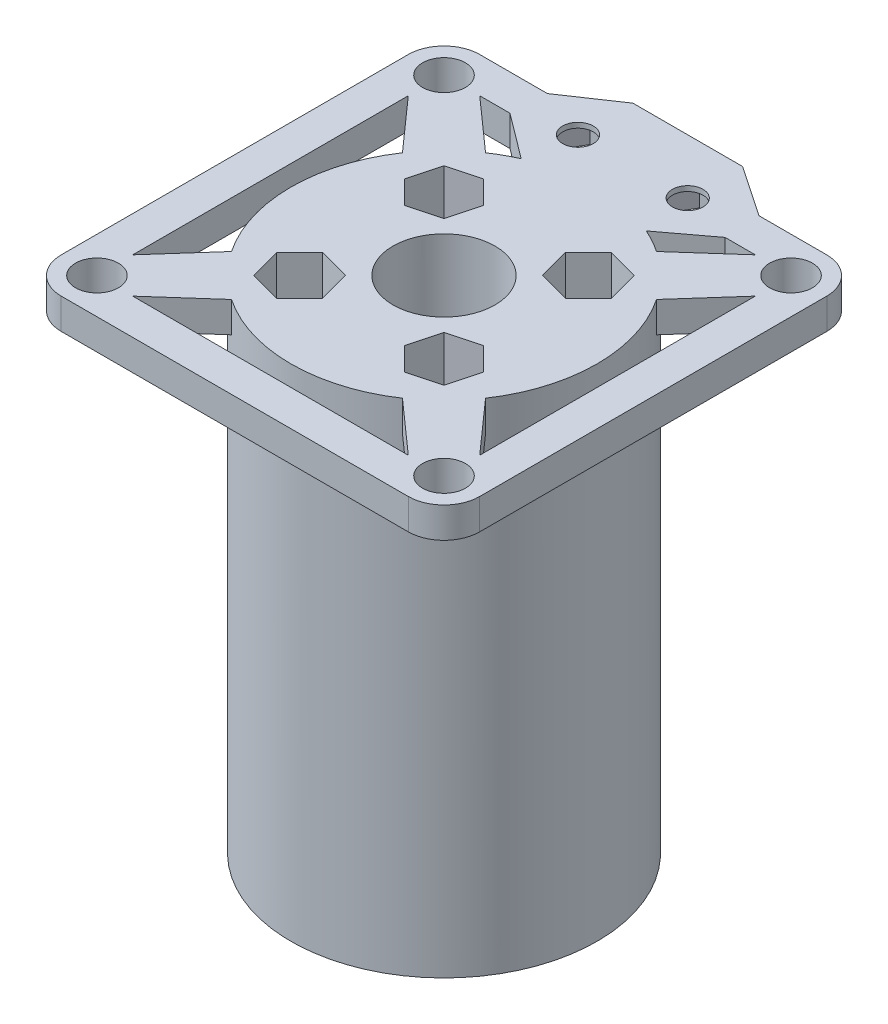
from build123d import *

# Parameters (mm, degrees)
SKETCH_1_R               = 15
SKETCH_1_R_2             = 5
EXTRUDE_4_DEPTH          = 3
SKETCH_1_R_3             = 3.5
SKETCH_1_R_4             = 2.1
EXTRUDE_4_2_DEPTH        = 3
EXTRUDE_5_DEPTH          = 3
PATTERN_CIRCULAR_2_COUNT = 4
SKETCH_6_R               = 3.5
SKETCH_6_R_2             = 2.1
EXTRUDE_6_DEPTH          = 3
PATTERN_CIRCULAR_3_COUNT = 4
SKETCH_7_R               = 15
SKETCH_7_R_2             = 5
EXTRUDE_7_DEPTH          = 46
CUT_EXTRUDE_1_DEPTH      = 46
PATTERN_CIRCULAR_4_COUNT = 4
SKETCH_11_R              = 1.5
CUT_EXTRUDE_2_DEPTH      = 3
PATTERN_CIRCULAR_5_COUNT = 4
EXTRUDE_8_DEPTH          = 3
EXTRUDE_9_DEPTH          = 3
EXTRUDE_10_DEPTH         = 3
EXTRUDE_11_DEPTH         = 3
EXTRUDE_13_DEPTH         = 3
EXTRUDE_14_DEPTH         = 3
CUT_EXTRUDE_3_DEPTH      = 2.5
SKETCH_19_R              = 1.5
CUT_EXTRUDE_4_DEPTH      = 2.5
SKETCH_20_R              = 1.5
CUT_EXTRUDE_5_DEPTH      = 2.5
SKETCH_21_R              = 15
SKETCH_21_R_2            = 5
EXTRUDE_15_DEPTH         = 3
SKETCH_22_R              = 1.5
CUT_EXTRUDE_6_DEPTH      = 3
PATTERN_CIRCULAR_6_COUNT = 4
EXTRUDE_16_DEPTH         = 3
CUT_EXTRUDE_7_DEPTH      = 3
SKETCH_25_R              = 15
SKETCH_25_R_2            = 5
EXTRUDE_17_DEPTH         = 43
SKETCH_27_R              = 1.5
CUT_EXTRUDE_8_DEPTH      = 46
SKETCH_28_R              = 2.75
CUT_EXTRUDE_9_DEPTH      = 43
SKETCH_29_R              = 1.5
CUT_EXTRUDE_10_DEPTH     = 46
PATTERN_CIRCULAR_7_COUNT = 4
CUT_EXTRUDE_11_DEPTH     = 43
PATTERN_CIRCULAR_8_COUNT = 4
SKETCH_31_R              = 26.244176336
CUT_EXTRUDE_12_DEPTH     = 100


with BuildPart() as part:
    # 草图1 → 凸台-拉伸4 (new body)
    with BuildSketch(Plane(origin=(0, 0, 0), x_dir=(1, 0, 0), z_dir=(0, 1, 0))):
        with Locations((-5.372895461, -8.931727747)):
            Circle(SKETCH_1_R)
        with Locations((-5.372895461, -8.931727747)):
            Circle(SKETCH_1_R_2, mode=Mode.SUBTRACT)
    extrude(amount=EXTRUDE_4_DEPTH)



with BuildPart() as body_2:
    # 草图1 → Extrude 4 2 (new body)
    with BuildSketch(Plane(origin=(0, 0, 0), x_dir=(1, 0, 0), z_dir=(0, 1, 0))):
        with Locations((-22.372895461, 8.068272253)):
            Circle(SKETCH_1_R_3)
        with Locations((-22.372895461, 8.068272253)):
            Circle(SKETCH_1_R_4, mode=Mode.SUBTRACT)
    extrude(amount=EXTRUDE_4_2_DEPTH)


with BuildPart() as part_1:
    add(part.part)

    add(body_2.part)  # 凸台-拉伸5 merges body 2
    # 草图5 → 凸台-拉伸5 (add)
    with BuildSketch(Plane(origin=(0, 0, 0), x_dir=(1, 0, 0), z_dir=(0, 1, 0))):
        Polygon((-22.372895461, 4.568272253), (-10.372895461, -8.931727747), (-10.372895461, -3.931727747), (-5.372895461, -3.931727747), (-18.872895461, 8.068272253), align=None)
    extrude_5 = extrude(amount=EXTRUDE_5_DEPTH)

    # 阵列(圆周)2: 凸台-拉伸5 ×4 about axis
    pattern_circular_2_axis = Axis((-5.372895461, 0, 8.931727747), (0, 1, 0))
    for i in range(1, PATTERN_CIRCULAR_2_COUNT):
        add(extrude_5.rotate(pattern_circular_2_axis, i * 360 / PATTERN_CIRCULAR_2_COUNT))

    # 草图6 → 凸台-拉伸6 (add)
    with BuildSketch(Plane(origin=(0, 3, 0), x_dir=(1, 0, 0), z_dir=(0, 1, 0))):
        with Locations((11.627104539, 8.068272253)):
            Circle(SKETCH_6_R)
        with Locations((11.627104539, 8.068272253)):
            Circle(SKETCH_6_R_2, mode=Mode.SUBTRACT)
    extrude_6 = extrude(amount=-EXTRUDE_6_DEPTH)

    # 阵列(圆周)3: 凸台-拉伸6 ×4 about axis
    pattern_circular_3_axis = Axis((-5.372895461, 0, 8.931727747), (0, 1, 0))
    for i in range(1, PATTERN_CIRCULAR_3_COUNT):
        add(extrude_6.rotate(pattern_circular_3_axis, i * 360 / PATTERN_CIRCULAR_3_COUNT))

    # 草图7 → 凸台-拉伸7 (add)
    with BuildSketch(Plane.XZ):
        with Locations((-5.372895461, 8.931727747)):
            Circle(SKETCH_7_R)
        with Locations((-5.372895461, 8.931727747)):
            Circle(SKETCH_7_R_2, mode=Mode.SUBTRACT)
    extrude(amount=EXTRUDE_7_DEPTH)

    # 草图9 → 切除-拉伸1 (cut)
    with BuildSketch(Plane(origin=(0, 3, 0), x_dir=(1, 0, 0), z_dir=(0, 1, 0))):
        Polygon((0.876311502, -19.070022006), (-1.369054096, -16.824656408), (-0.547193246, -13.757429961), (2.520033201, -12.935569112), (4.765398798, -15.180934709), (3.943537949, -18.248161156), align=None)
    cut_extrude_1 = extrude(amount=-CUT_EXTRUDE_1_DEPTH, mode=Mode.SUBTRACT)

    # 阵列(圆周)4: 切除-拉伸1 ×4 about axis
    pattern_circular_4_axis = Axis((-5.372895461, 0, 8.931727747), (0, 1, 0))
    for i in range(1, PATTERN_CIRCULAR_4_COUNT):
        add(cut_extrude_1.rotate(pattern_circular_4_axis, i * 360 / PATTERN_CIRCULAR_4_COUNT), mode=Mode.SUBTRACT)

    # 草图11 → 切除-拉伸2 (cut)
    with BuildSketch(Plane(origin=(0, -43, 0), x_dir=(1, 0, 0), z_dir=(0, 1, 0))):
        with Locations((1.698172351, -1.860659935)):
            Circle(SKETCH_11_R)
    cut_extrude_2 = extrude(amount=-CUT_EXTRUDE_2_DEPTH, mode=Mode.SUBTRACT)

    # 阵列(圆周)5: 切除-拉伸2 ×4 about axis
    pattern_circular_5_axis = Axis((-5.372895461, 0, 8.931727747), (0, 1, 0))
    for i in range(1, PATTERN_CIRCULAR_5_COUNT):
        add(cut_extrude_2.rotate(pattern_circular_5_axis, i * 360 / PATTERN_CIRCULAR_5_COUNT), mode=Mode.SUBTRACT)

    # 草图12 → 凸台-拉伸8 (add)
    with BuildSketch(Plane(origin=(0, 3, 0), x_dir=(1, 0, 0), z_dir=(0, 1, 0))):
        Polygon((15.127104539, 8.068272253), (15.127104539, -25.931727747), (11.627104539, -22.431727747), (11.627104539, 4.568272253), align=None)
    extrude(amount=-EXTRUDE_8_DEPTH)

    # 草图13 → 凸台-拉伸9 (add)
    with BuildSketch(Plane(origin=(0, 3, 0), x_dir=(1, 0, 0), z_dir=(0, 1, 0))):
        Polygon((11.627104539, 11.568272253), (-22.372895461, 11.568272253), (-18.872895461, 8.068272253), (8.127104539, 8.068272253), align=None)
    extrude(amount=-EXTRUDE_9_DEPTH)

    # 草图14 → 凸台-拉伸10 (add)
    with BuildSketch(Plane(origin=(0, 3, 0), x_dir=(1, 0, 0), z_dir=(0, 1, 0))):
        Polygon((-25.872895461, 8.068272253), (-25.872895461, -25.931727747), (-22.372895461, -22.431727747), (-22.372895461, 4.568272253), align=None)
    extrude(amount=-EXTRUDE_10_DEPTH)

    # 草图15 → 凸台-拉伸11 (add)
    with BuildSketch(Plane(origin=(0, 3, 0), x_dir=(1, 0, 0), z_dir=(0, 1, 0))):
        Polygon((-22.372895461, -29.431727747), (11.627104539, -29.431727747), (8.127104539, -25.931727747), (-18.872895461, -25.931727747), align=None)
    extrude(amount=-EXTRUDE_11_DEPTH)

    # 草图16 → 凸台-拉伸13 (add)
    with BuildSketch(Plane.XZ):
        Polygon((-10.747895461, -4.193272253), (0.002104539, -4.193272253), (5.163560245, -8.068272253), (4.99115505, -11.568272253), (0.002104539, -14.943272253), (-10.747895461, -14.943272253), (-15.736945971, -11.568272253), (-15.909351166, -8.068272253), align=None)
        Polygon((-7.57246898, -9.568272253), (-9.16018222, -6.818272253), (-12.335608701, -6.818272253), (-13.923321941, -9.568272253), (-12.335608701, -12.318272253), (-9.16018222, -12.318272253), align=None, mode=Mode.SUBTRACT)
        Polygon((3.17753102, -9.568272253), (1.58981778, -6.818272253), (-1.585608701, -6.818272253), (-3.173321941, -9.568272253), (-1.585608701, -12.318272253), (1.58981778, -12.318272253), align=None, mode=Mode.SUBTRACT)
    extrude(amount=-EXTRUDE_13_DEPTH)

    # 草图18 → 凸台-拉伸14 (add)
    with BuildSketch(Plane.XZ):
        Polygon((-7.57246898, -9.568272253), (-9.16018222, -6.818272253), (-12.335608701, -6.818272253), (-13.923321941, -9.568272253), (-12.335608701, -12.318272253), (-9.16018222, -12.318272253), align=None)
        Polygon((3.17753102, -9.568272253), (1.58981778, -6.818272253), (-1.585608701, -6.818272253), (-3.173321941, -9.568272253), (-1.585608701, -12.318272253), (1.58981778, -12.318272253), align=None)
    extrude(amount=-EXTRUDE_14_DEPTH)

    # 草图17 → 切除-拉伸3 (cut)
    with BuildSketch(Plane.XZ):
        Polygon((-7.57246898, -9.568272253), (-9.16018222, -6.818272253), (-12.335608701, -6.818272253), (-13.923321941, -9.568272253), (-12.335608701, -12.318272253), (-9.16018222, -12.318272253), align=None)
        Polygon((3.17753102, -9.568272253), (1.58981778, -6.818272253), (-1.585608701, -6.818272253), (-3.173321941, -9.568272253), (-1.585608701, -12.318272253), (1.58981778, -12.318272253), align=None)
    extrude(amount=-CUT_EXTRUDE_3_DEPTH, mode=Mode.SUBTRACT)

    # 草图19 → 切除-拉伸4 (cut)
    with BuildSketch(Plane.XZ.offset(-2.5)):
        with Locations((0.002104539, -9.568272253)):
            Circle(SKETCH_19_R)
    extrude(amount=-CUT_EXTRUDE_4_DEPTH, mode=Mode.SUBTRACT)

    # 草图20 → 切除-拉伸5 (cut)
    with BuildSketch(Plane.XZ.offset(-2.5)):
        with Locations((-10.747895461, -9.568272253)):
            Circle(SKETCH_20_R)
    extrude(amount=-CUT_EXTRUDE_5_DEPTH, mode=Mode.SUBTRACT)

    # 草图8 → 凸台-拉伸16 (add)
    with BuildSketch(Plane.XZ.offset(46)):
        Polygon((3.943537949, 18.248161156), (0.876311502, 19.070022006), (-1.369054096, 16.824656408), (-0.547193246, 13.757429961), (2.520033201, 12.935569112), (4.765398798, 15.180934709), align=None)
    extrude(amount=EXTRUDE_16_DEPTH)

    # 草图24 → 切除-拉伸7 (cut)
    with BuildSketch(Plane.XZ.offset(49)):
        Polygon((4.765398798, 15.180934709), (3.943537949, 18.248161156), (0.876311502, 19.070022006), (-1.369054096, 16.824656408), (-0.547193246, 13.757429961), (2.520033201, 12.935569112), align=None)
    extrude(amount=-CUT_EXTRUDE_7_DEPTH, mode=Mode.SUBTRACT)


with BuildPart() as body_2_2:
    # 草图21 → 凸台-拉伸15 (new body)
    with BuildSketch(Plane(origin=(0, 0, 0), x_dir=(1, 0, 0), z_dir=(0, 1, 0))):
        with Locations((59.665545214, -8.931727747)):
            Circle(SKETCH_21_R)
        with Locations((59.665545214, -8.931727747)):
            Circle(SKETCH_21_R_2, mode=Mode.SUBTRACT)
    extrude(amount=EXTRUDE_15_DEPTH)

    # 草图22 → 切除-拉伸6 (cut)
    with BuildSketch(Plane.XZ):
        with Locations((59.665545214, 18.931727747)):
            Circle(SKETCH_22_R)
    cut_extrude_6 = extrude(amount=-CUT_EXTRUDE_6_DEPTH, mode=Mode.SUBTRACT)

    # 阵列(圆周)6: 切除-拉伸6 ×4 about axis
    pattern_circular_6_axis = Axis((59.665545214, 0, 8.931727747), (0, 1, 0))
    for i in range(1, PATTERN_CIRCULAR_6_COUNT):
        add(cut_extrude_6.rotate(pattern_circular_6_axis, i * 360 / PATTERN_CIRCULAR_6_COUNT), mode=Mode.SUBTRACT)

    # 草图25 → 凸台-拉伸17 (add)
    with BuildSketch(Plane.XZ):
        with Locations((59.665545214, 8.931727747)):
            Circle(SKETCH_25_R)
        with Locations((59.665545214, 8.931727747)):
            Circle(SKETCH_25_R_2, mode=Mode.SUBTRACT)
    extrude(amount=EXTRUDE_17_DEPTH)

    # 草图27 → 切除-拉伸8 (cut)
    with BuildSketch(Plane(origin=(0, 3, 0), x_dir=(1, 0, 0), z_dir=(0, 1, 0))):
        with Locations((59.665545214, 1.068272253)):
            Circle(SKETCH_27_R)
        with Locations((69.665545214, -8.931727747)):
            Circle(SKETCH_27_R)
        with Locations((59.665545214, -18.931727747)):
            Circle(SKETCH_27_R)
        with Locations((49.665545214, -8.931727747)):
            Circle(SKETCH_27_R)
    extrude(amount=-CUT_EXTRUDE_8_DEPTH, mode=Mode.SUBTRACT)

    # 草图28 → 切除-拉伸9 (cut)
    with BuildSketch(Plane.XZ.offset(43)):
        with Locations((59.665545214, 18.931727747)):
            Circle(SKETCH_28_R)
        with Locations((49.665545214, 8.931727747)):
            Circle(SKETCH_28_R)
        with Locations((59.665545214, -1.068272253)):
            Circle(SKETCH_28_R)
        with Locations((69.665545214, 8.931727747)):
            Circle(SKETCH_28_R)
    extrude(amount=-CUT_EXTRUDE_9_DEPTH, mode=Mode.SUBTRACT)

    # 草图29 → 切除-拉伸10 (cut)
    with BuildSketch(Plane(origin=(0, 3, 0), x_dir=(1, 0, 0), z_dir=(0, 1, 0))):
        with Locations((66.736613026, -1.860659935)):
            Circle(SKETCH_29_R)
    cut_extrude_10 = extrude(amount=-CUT_EXTRUDE_10_DEPTH, mode=Mode.SUBTRACT)

    # 阵列(圆周)7: 切除-拉伸10 ×4 about axis
    pattern_circular_7_axis = Axis((59.665545214, 0, 8.931727747), (0, 1, 0))
    for i in range(1, PATTERN_CIRCULAR_7_COUNT):
        add(cut_extrude_10.rotate(pattern_circular_7_axis, i * 360 / PATTERN_CIRCULAR_7_COUNT), mode=Mode.SUBTRACT)

    # 草图30 → 切除-拉伸11 (cut)
    with BuildSketch(Plane(origin=(0, 3, 0), x_dir=(1, 0, 0), z_dir=(0, 1, 0))):
        Polygon((64.491247429, -4.106025533), (67.558473876, -4.927886382), (69.803839473, -2.682520785), (68.981978624, 0.384705662), (65.914752177, 1.206566512), (63.669386579, -1.038799086), align=None)
    cut_extrude_11 = extrude(amount=-CUT_EXTRUDE_11_DEPTH, mode=Mode.SUBTRACT)

    # 阵列(圆周)8: 切除-拉伸11 ×4 about axis
    pattern_circular_8_axis = Axis((59.665545214, 0, 8.931727747), (0, 1, 0))
    for i in range(1, PATTERN_CIRCULAR_8_COUNT):
        add(cut_extrude_11.rotate(pattern_circular_8_axis, i * 360 / PATTERN_CIRCULAR_8_COUNT), mode=Mode.SUBTRACT)

    # 草图31 → 切除-拉伸12 (cut)
    with BuildSketch(Plane(origin=(0, 3, 0), x_dir=(1, 0, 0), z_dir=(0, 1, 0))):
        with Locations((59.665545214, -8.931727747)):
            Circle(SKETCH_31_R)
    extrude(amount=-CUT_EXTRUDE_12_DEPTH, mode=Mode.SUBTRACT)


solid = part_1.part
